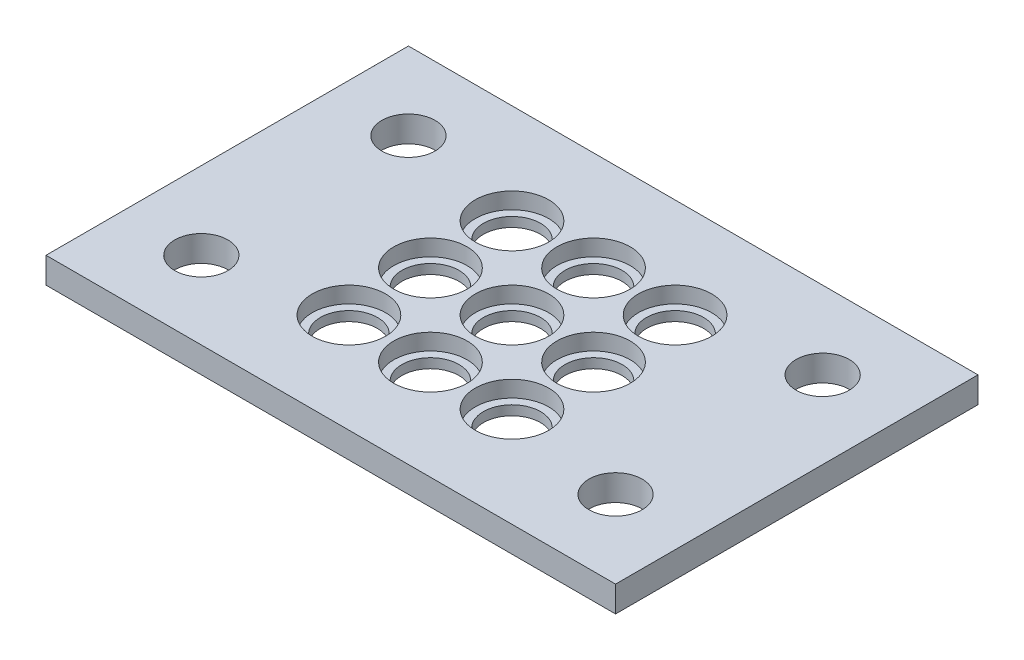
from build123d import *

# Parameters (mm, degrees)
SKETCH1_W           = 69.85
SKETCH1_H           = 44.45
SKETCH1_R           = 3.2639
SKETCH1_R_2         = 3.5
BOSS_EXTRUDE1_DEPTH = 3.175
SKETCH2_R           = 4.5
CUT_EXTRUDE1_DEPTH  = 2


with BuildPart() as part:
    # Sketch1 → Boss-Extrude1 (new body)
    with BuildSketch(Plane(origin=(0, 0, 0), x_dir=(1, 0, 0), z_dir=(0, 1, 0))):
        with Locations((34.925, 22.225)):
            Rectangle(SKETCH1_W, SKETCH1_H)
        with Locations((9.525, 34.925)):
            Circle(SKETCH1_R, mode=Mode.SUBTRACT)
        with Locations((60.325, 34.925)):
            Circle(SKETCH1_R, mode=Mode.SUBTRACT)
        with Locations((9.525, 9.525)):
            Circle(SKETCH1_R, mode=Mode.SUBTRACT)
        with Locations((60.325, 9.525)):
            Circle(SKETCH1_R, mode=Mode.SUBTRACT)
        with Locations((44.925, 32.225)):
            Circle(SKETCH1_R_2, mode=Mode.SUBTRACT)
        with Locations((34.925, 32.225)):
            Circle(SKETCH1_R_2, mode=Mode.SUBTRACT)
        with Locations((24.925, 32.225)):
            Circle(SKETCH1_R_2, mode=Mode.SUBTRACT)
        with Locations((34.925, 22.225)):
            Circle(SKETCH1_R_2, mode=Mode.SUBTRACT)
        with Locations((24.925, 22.225)):
            Circle(SKETCH1_R_2, mode=Mode.SUBTRACT)
        with Locations((34.925, 12.225)):
            Circle(SKETCH1_R_2, mode=Mode.SUBTRACT)
        with Locations((24.925, 12.225)):
            Circle(SKETCH1_R_2, mode=Mode.SUBTRACT)
        with Locations((44.925, 22.225)):
            Circle(SKETCH1_R_2, mode=Mode.SUBTRACT)
        with Locations((44.925, 12.225)):
            Circle(SKETCH1_R_2, mode=Mode.SUBTRACT)
    extrude(amount=BOSS_EXTRUDE1_DEPTH)

    # Sketch2 → Cut-Extrude1 (cut)
    with BuildSketch(Plane(origin=(0, 3.175, 0), x_dir=(1, 0, 0), z_dir=(0, 1, 0))):
        with Locations((44.925, 12.225)):
            Circle(SKETCH2_R)
        with Locations((34.925, 12.225)):
            Circle(SKETCH2_R)
        with Locations((24.925, 12.225)):
            Circle(SKETCH2_R)
        with Locations((34.925, 22.225)):
            Circle(SKETCH2_R)
        with Locations((24.925, 22.225)):
            Circle(SKETCH2_R)
        with Locations((34.925, 32.225)):
            Circle(SKETCH2_R)
        with Locations((24.925, 32.225)):
            Circle(SKETCH2_R)
        with Locations((44.925, 22.225)):
            Circle(SKETCH2_R)
        with Locations((44.925, 32.225)):
            Circle(SKETCH2_R)
    extrude(amount=-CUT_EXTRUDE1_DEPTH, mode=Mode.SUBTRACT)


solid = part.part
